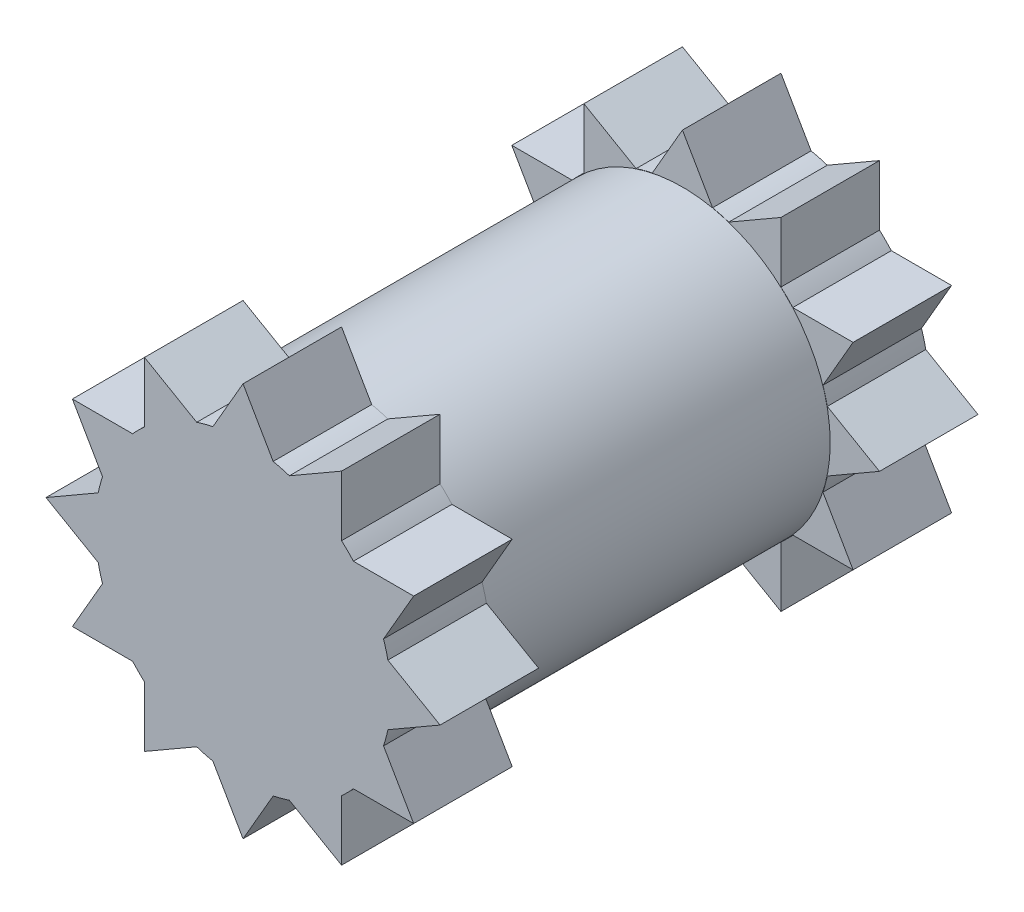
from build123d import *

# Parameters (mm, degrees)
IZIM1_R                     = 2
Y_KSEKLIK_EKSTR_ZYON1_DEPTH = 1
IZIM2_R                     = 1.5
Y_KSEKLIK_EKSTR_ZYON2_DEPTH = 1.73
KES_EKSTR_ZYON1_DEPTH       = 2


with BuildPart() as part:
    # Çizim1 → Yükseklik-Ekstrüzyon1 (new body)
    with BuildSketch(Plane.XY):
        Circle(IZIM1_R)
    extrude(amount=Y_KSEKLIK_EKSTR_ZYON1_DEPTH)

    # Çizim2 → Yükseklik-Ekstrüzyon2 (add)
    with BuildSketch(Plane.XY.offset(1)):
        Circle(IZIM2_R)
    extrude(amount=Y_KSEKLIK_EKSTR_ZYON2_DEPTH)

    # Çizim3 → Kes-Ekstrüzyon1 (cut)
    with BuildSketch(Plane(origin=(0, 0, 0), x_dir=(-1, 0, 0), z_dir=(0, 0, -1))):
        with BuildLine():
            Line((-0.305902622, 1.470161116), (0, 2))
            ThreePointArc((0, 2), (-0.51763809, 1.931851653), (-1, 1.732050808))
            Line((-1, 1.732050808), (-0.470161116, 1.426148185))
            ThreePointArc((-0.470161116, 1.426148185), (-0.388655395, 1.45048168), (-0.305902622, 1.470161116))
        make_face()
        with BuildLine():
            Line((-1, 1.120245563), (-1, 1.732050808))
            ThreePointArc((-1, 1.732050808), (-1.414213562, 1.414213562), (-1.732050808, 1))
            Line((-1.732050808, 1), (-1.120245563, 1))
            ThreePointArc((-1.120245563, 1), (-1.061826285, 1.061826285), (-1, 1.120245563))
        make_face()
        with BuildLine():
            Line((-1.426148185, 0.470161116), (-1.732050808, 1))
            ThreePointArc((-1.732050808, 1), (-1.931851653, 0.51763809), (-2, 0))
            Line((-2, 0), (-1.470161116, 0.305902622))
            ThreePointArc((-1.470161116, 0.305902622), (-1.45048168, 0.388655395), (-1.426148185, 0.470161116))
        make_face()
        with BuildLine():
            Line((-1.470161116, -0.305902622), (-2, 0))
            ThreePointArc((-2, 0), (-1.931851653, -0.51763809), (-1.732050808, -1))
            Line((-1.732050808, -1), (-1.426148185, -0.470161116))
            ThreePointArc((-1.426148185, -0.470161116), (-1.45048168, -0.388655395), (-1.470161116, -0.305902622))
        make_face()
        with BuildLine():
            Line((-1.120245563, -1), (-1.732050808, -1))
            ThreePointArc((-1.732050808, -1), (-1.414213562, -1.414213562), (-1, -1.732050808))
            Line((-1, -1.732050808), (-1, -1.120245563))
            ThreePointArc((-1, -1.120245563), (-1.061826285, -1.061826285), (-1.120245563, -1))
        make_face()
        with BuildLine():
            ThreePointArc((-1, -1.732050808), (-0.51763809, -1.931851653), (0, -2))
            Line((0, -2), (-0.305902622, -1.470161116))
            ThreePointArc((-0.305902622, -1.470161116), (-0.388655395, -1.45048168), (-0.470161116, -1.426148185))
            Line((-0.470161116, -1.426148185), (-1, -1.732050808))
        make_face()
        with BuildLine():
            ThreePointArc((0, -2), (0.51763809, -1.931851653), (1, -1.732050808))
            Line((1, -1.732050808), (0.470161116, -1.426148185))
            ThreePointArc((0.470161116, -1.426148185), (0.388655395, -1.45048168), (0.305902622, -1.470161116))
            Line((0.305902622, -1.470161116), (0, -2))
        make_face()
        with BuildLine():
            ThreePointArc((1, -1.732050808), (1.414213562, -1.414213562), (1.732050808, -1))
            Line((1.732050808, -1), (1.120245563, -1))
            ThreePointArc((1.120245563, -1), (1.061826285, -1.061826285), (1, -1.120245563))
            Line((1, -1.120245563), (1, -1.732050808))
        make_face()
        with BuildLine():
            ThreePointArc((1.732050808, -1), (1.931851653, -0.51763809), (2, 0))
            Line((2, 0), (1.470161116, -0.305902622))
            ThreePointArc((1.470161116, -0.305902622), (1.45048168, -0.388655395), (1.426148185, -0.470161116))
            Line((1.426148185, -0.470161116), (1.732050808, -1))
        make_face()
        with BuildLine():
            ThreePointArc((2, 0), (1.931851653, 0.51763809), (1.732050808, 1))
            Line((1.732050808, 1), (1.426148185, 0.470161116))
            ThreePointArc((1.426148185, 0.470161116), (1.45048168, 0.388655395), (1.470161116, 0.305902622))
            Line((1.470161116, 0.305902622), (2, 0))
        make_face()
        with BuildLine():
            ThreePointArc((1.732050808, 1), (1.414213562, 1.414213562), (1, 1.732050808))
            Line((1, 1.732050808), (1, 1.120245563))
            ThreePointArc((1, 1.120245563), (1.061826285, 1.061826285), (1.120245563, 1))
            Line((1.120245563, 1), (1.732050808, 1))
        make_face()
        with BuildLine():
            Line((0.470161116, 1.426148185), (1, 1.732050808))
            ThreePointArc((1, 1.732050808), (0.51763809, 1.931851653), (0, 2))
            Line((0, 2), (0.305902622, 1.470161116))
            ThreePointArc((0.305902622, 1.470161116), (0.388655395, 1.45048168), (0.470161116, 1.426148185))
        make_face()
    extrude(amount=-KES_EKSTR_ZYON1_DEPTH, mode=Mode.SUBTRACT)

    # Aynalama3: part across plane


with BuildPart() as part_1:
    add(part.part)
    add(part.part.mirror(Plane.XY.offset(2.73)))


solid = part_1.part
